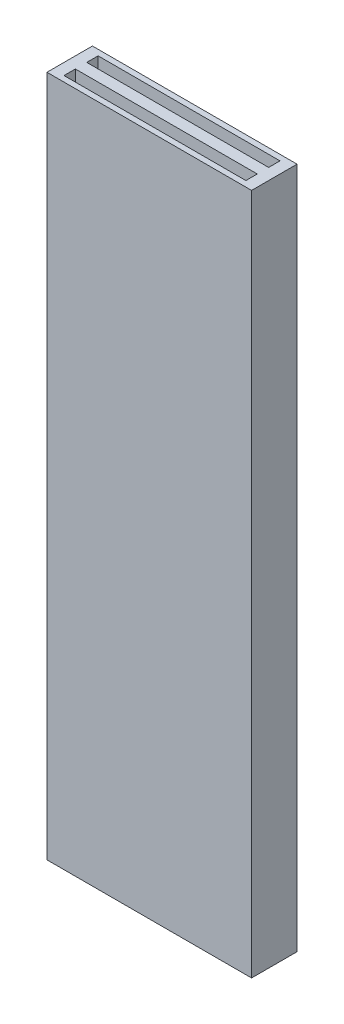
from build123d import *

# Parameters (mm, degrees)
SKETCH1_W           = 9
SKETCH1_H           = 2
BOSS_EXTRUDE1_DEPTH = 15
CUT_EXTRUDE1_START  = -31
SKETCH2_W           = 8
SKETCH2_H           = 0.5
CUT_EXTRUDE1_DEPTH  = 32


with BuildPart() as part:
    # Sketch1 → Boss-Extrude1 (new body, symmetric)
    with BuildSketch(Plane(origin=(0, 0, 0), x_dir=(1, 0, 0), z_dir=(0, 1, 0))):
        Rectangle(SKETCH1_W, SKETCH1_H)
    extrude(amount=BOSS_EXTRUDE1_DEPTH, both=True)

    # Sketch2 → Cut-Extrude1 (cut)
    with BuildSketch(Plane(origin=(0, 15, 0), x_dir=(1, 0, 0), z_dir=(0, 1, 0)).offset(CUT_EXTRUDE1_START)):
        with Locations((0, 0.5)):
            Rectangle(SKETCH2_W, SKETCH2_H)
    cut_extrude1 = extrude(amount=CUT_EXTRUDE1_DEPTH, mode=Mode.SUBTRACT)

    # Mirror1: Cut-Extrude1 across plane
    add(cut_extrude1.mirror(Plane.XY), mode=Mode.SUBTRACT)


solid = part.part
